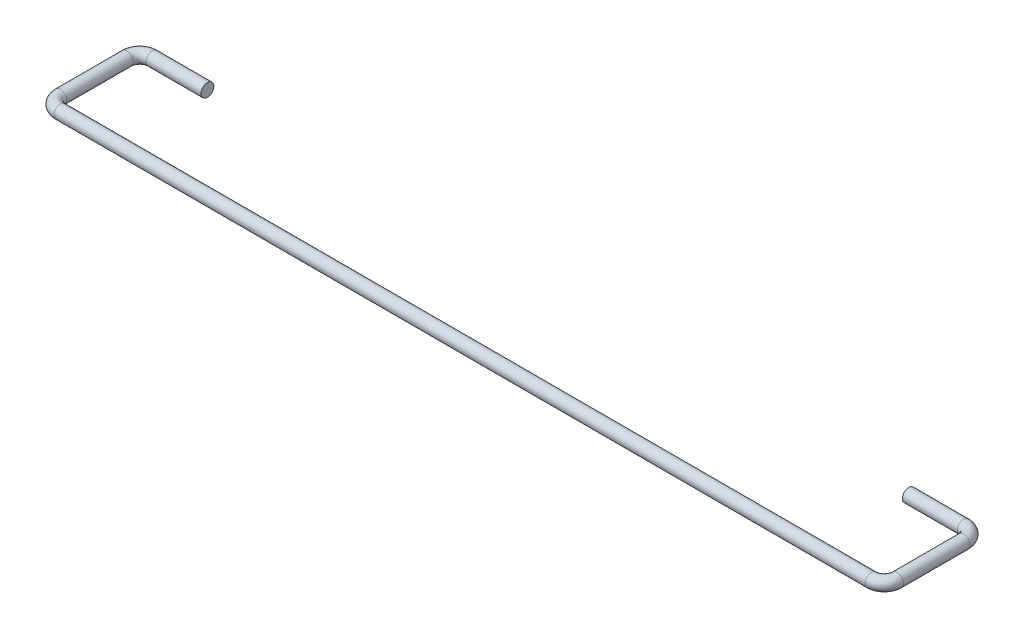
from build123d import *

# Parameters (mm, degrees)
SEGMENT_R = 0.8


with BuildPart() as part:
    # Wire 2: sweep along a path in Path
    with BuildLine(Plane(origin=(0, 0, 0), x_dir=(1, 0, 0), z_dir=(0, 1, 0))) as wire_2_path:
        Line((-43.75, 11.5), (-50.6, 11.5))
        ThreePointArc((-50.6, 11.5), (-51.73137085, 11.03137085), (-52.2, 9.9))
        Line((-52.2, 9.9), (-52.2, 1.6))
        ThreePointArc((-52.2, 1.6), (-51.73137085, 0.46862915), (-50.6, 0))
        Line((-50.6, 0), (50.6, 0))
        ThreePointArc((50.6, 0), (51.73137085, 0.46862915), (52.2, 1.6))
        Line((52.2, 1.6), (52.2, 9.9))
        ThreePointArc((52.2, 9.9), (51.73137085, 11.03137085), (50.6, 11.5))
        Line((50.6, 11.5), (43.75, 11.5))
    # Segment → Wire 2 (sweep)
    with BuildSketch(Plane(origin=(-43.75, 0, 0), x_dir=(0, 0, -1), z_dir=(1, 0, 0))):
        with Locations((11.5, 0)):
            Circle(SEGMENT_R)
    sweep(path=wire_2_path.line)


solid = part.part
